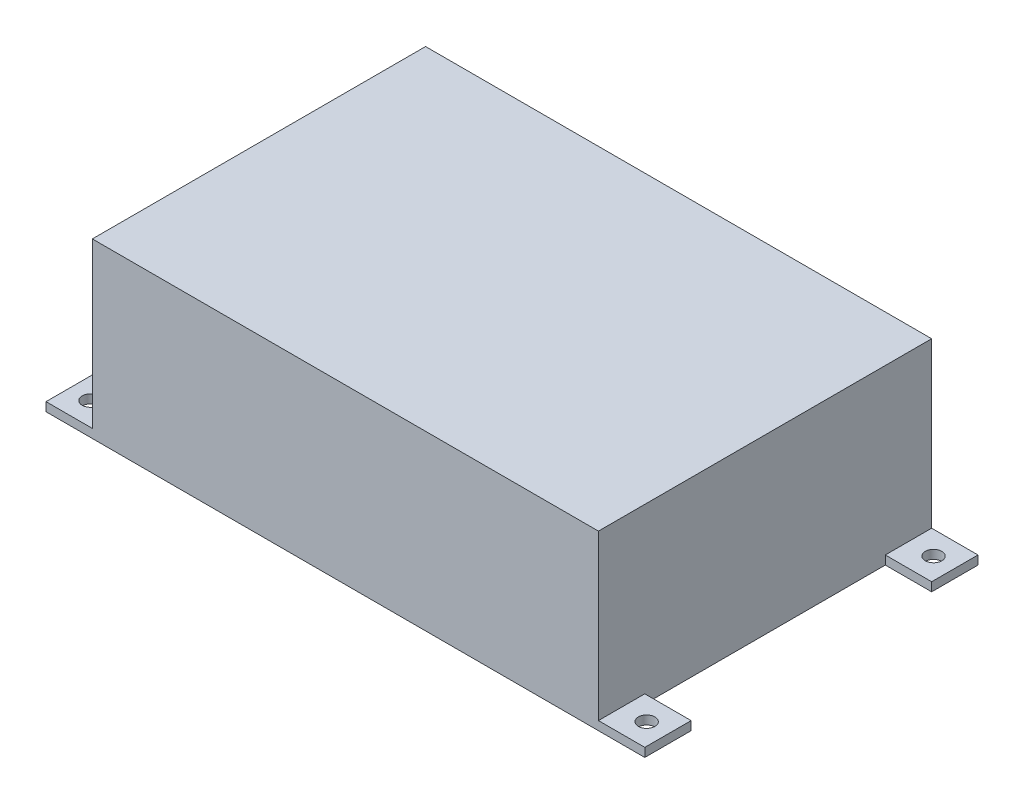
from build123d import *

# Parameters (mm, degrees)
SKETCH1_W            = 202
SKETCH1_H            = 133
BOSS_EXTRUDE1_DEPTH  = 69
SKETCH2_W            = 18.5
SKETCH2_H            = 18.5
BOSS_EXTRUDE2_DEPTH  = 3.5
M6_CLEARANCE_HOLE1_D = 6.6


with BuildPart() as part:
    # Sketch1 → Boss-Extrude1 (new body)
    with BuildSketch(Plane(origin=(0, 0, 0), x_dir=(1, 0, 0), z_dir=(0, 1, 0))):
        with Locations((101, 66.5)):
            Rectangle(SKETCH1_W, SKETCH1_H)
    extrude(amount=BOSS_EXTRUDE1_DEPTH)

    # Sketch2 → Boss-Extrude2 (add)
    with BuildSketch(Plane(origin=(0, 0, 0), x_dir=(1, 0, 0), z_dir=(0, 1, 0))):
        with Locations((-9.25, 123.75)):
            Rectangle(SKETCH2_W, SKETCH2_H)
        with Locations((-9.25, 9.25)):
            Rectangle(SKETCH2_W, SKETCH2_H)
        with Locations((211.25, 9.25)):
            Rectangle(SKETCH2_W, SKETCH2_H)
        with Locations((211.25, 123.75)):
            Rectangle(SKETCH2_W, SKETCH2_H)
    extrude(amount=BOSS_EXTRUDE2_DEPTH)

    # M6 Clearance Hole1 (through all)
    with Locations(Plane(origin=(0, 3.5, 0), x_dir=(1, 0, 0), z_dir=(0, 1, 0))):
        with Locations((-10, 123.75), (-10, 9.25), (212, 9.25), (212, 123.75)):
            Hole(M6_CLEARANCE_HOLE1_D / 2)


solid = part.part
